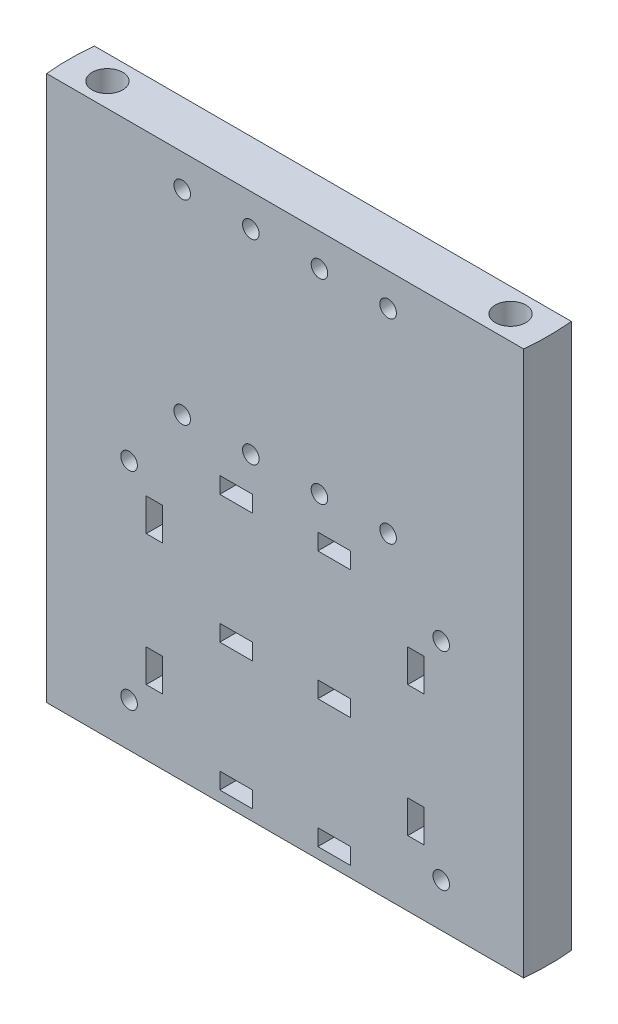
from build123d import *

# Parameters (mm, degrees)
BOSS_EXTRUDE1_DEPTH     = 127
F_1_4_CLEARANCE_HOLE1_D = 7.14248
F_8_CLEARANCE_HOLE1_D   = 3.8608
SKETCH19_W              = 7.62
SKETCH19_H              = 3.81
SKETCH19_W_2            = 3.81
SKETCH19_H_2            = 7.62
CUT_EXTRUDE3_DEPTH      = 12.118122863
F_8_CLEARANCE_HOLE2_D   = 3.8608
F_8_CLEARANCE_HOLE3_D   = 3.8608
SKETCH10_W              = 64.77
SKETCH10_H              = 63.5
CUT_EXTRUDE4_DEPTH      = 5.08
SKETCH36_R              = 76.2
SKETCH36_R_2            = 55.88
CUT_EXTRUDE5_DEPTH      = 128
SKETCH37_W              = 80.772
SKETCH37_H              = 63.5
CUT_EXTRUDE6_DEPTH      = 5.08


with BuildPart() as part:
    # Sketch1 → Boss-Extrude1 (new body)
    with BuildSketch(Plane(origin=(0, 0, 0), x_dir=(1, 0, 0), z_dir=(0, 1, 0))):
        with BuildLine():
            Line((-60.706, 5.559061432), (60.706, 5.559061432))
            ThreePointArc((60.706, 5.559061432), (60.96, 0), (60.706, -5.559061432))
            Line((60.706, -5.559061432), (-60.706, -5.559061432))
            ThreePointArc((-60.706, -5.559061432), (-60.96, 0), (-60.706, 5.559061432))
        make_face()
    extrude(amount=BOSS_EXTRUDE1_DEPTH)

    # 1/4 Clearance Hole1 (through all)
    with Locations(Plane(origin=(0, 127, 0), x_dir=(1, 0, 0), z_dir=(0, 1, 0))):
        with Locations((-46.99, 0), (46.99, 0)):
            Hole(F_1_4_CLEARANCE_HOLE1_D / 2)

    # #8 Clearance Hole1 (through all)
    with Locations(Plane(origin=(0, 0, -5.559061432), x_dir=(-1, 0, 0), z_dir=(0, 0, -1))):
        with Locations((-8.001, 119.38), (-8.001, 73.914), (8.001, 73.914), (8.001, 119.38)):
            Hole(F_8_CLEARANCE_HOLE1_D / 2)

    # Sketch19 → Cut-Extrude3 (cut, through all)
    with BuildSketch(Plane(origin=(0, 0, -5.559061432), x_dir=(-1, 0, 0), z_dir=(0, 0, -1))):
        with Locations((-11.43, 34.29)):
            Rectangle(SKETCH19_W, SKETCH19_H)
        with Locations((30.48, 49.53)):
            Rectangle(SKETCH19_W_2, SKETCH19_H_2)
        with Locations((-11.43, 64.135)):
            Rectangle(SKETCH19_W, SKETCH19_H)
        with Locations((11.43, 64.135)):
            Rectangle(SKETCH19_W, SKETCH19_H)
        with Locations((-11.43, 4.445)):
            Rectangle(SKETCH19_W, SKETCH19_H)
        with Locations((11.43, 4.445)):
            Rectangle(SKETCH19_W, SKETCH19_H)
        with Locations((-30.48, 49.53)):
            Rectangle(SKETCH19_W_2, SKETCH19_H_2)
        with Locations((30.48, 19.05)):
            Rectangle(SKETCH19_W_2, SKETCH19_H_2)
        with Locations((-30.48, 19.05)):
            Rectangle(SKETCH19_W_2, SKETCH19_H_2)
        with Locations((11.43, 34.29)):
            Rectangle(SKETCH19_W, SKETCH19_H)
    extrude(amount=-CUT_EXTRUDE3_DEPTH, mode=Mode.SUBTRACT)

    # #8 Clearance Hole2 (through all)
    with Locations(Plane(origin=(0, 0, -5.559061432), x_dir=(-1, 0, 0), z_dir=(0, 0, -1))):
        with Locations((-24.003, 119.38), (-24.003, 73.914), (24.003, 73.914), (24.003, 119.38)):
            Hole(F_8_CLEARANCE_HOLE2_D / 2)

    # #8 Clearance Hole3 (through all)
    with Locations(Plane(origin=(0, 0, -5.559061432), x_dir=(-1, 0, 0), z_dir=(0, 0, -1))):
        with Locations((-36.3855, 58.42), (-36.3855, 10.16), (36.3855, 10.16), (36.3855, 58.42)):
            Hole(F_8_CLEARANCE_HOLE3_D / 2)

    # Sketch10 → Cut-Extrude4 (cut)
    with BuildSketch(Plane(origin=(0, 0, -5.559061432), x_dir=(-1, 0, 0), z_dir=(0, 0, -1))):
        with Locations((0, 34.29)):
            Rectangle(SKETCH10_W, SKETCH10_H)
    extrude(amount=-CUT_EXTRUDE4_DEPTH, mode=Mode.SUBTRACT)

    # Sketch36 → Cut-Extrude5 (cut, through all)
    with BuildSketch(Plane(origin=(0, 127, 0), x_dir=(1, 0, 0), z_dir=(0, 1, 0))):
        Circle(SKETCH36_R)
        Circle(SKETCH36_R_2, mode=Mode.SUBTRACT)
    extrude(amount=-CUT_EXTRUDE5_DEPTH, mode=Mode.SUBTRACT)

    # Sketch37 → Cut-Extrude6 (cut)
    with BuildSketch(Plane(origin=(0, 0, -5.559061432), x_dir=(-1, 0, 0), z_dir=(0, 0, -1))):
        with Locations((0, 34.29)):
            Rectangle(SKETCH37_W, SKETCH37_H)
    extrude(amount=-CUT_EXTRUDE6_DEPTH, mode=Mode.SUBTRACT)


solid = part.part
